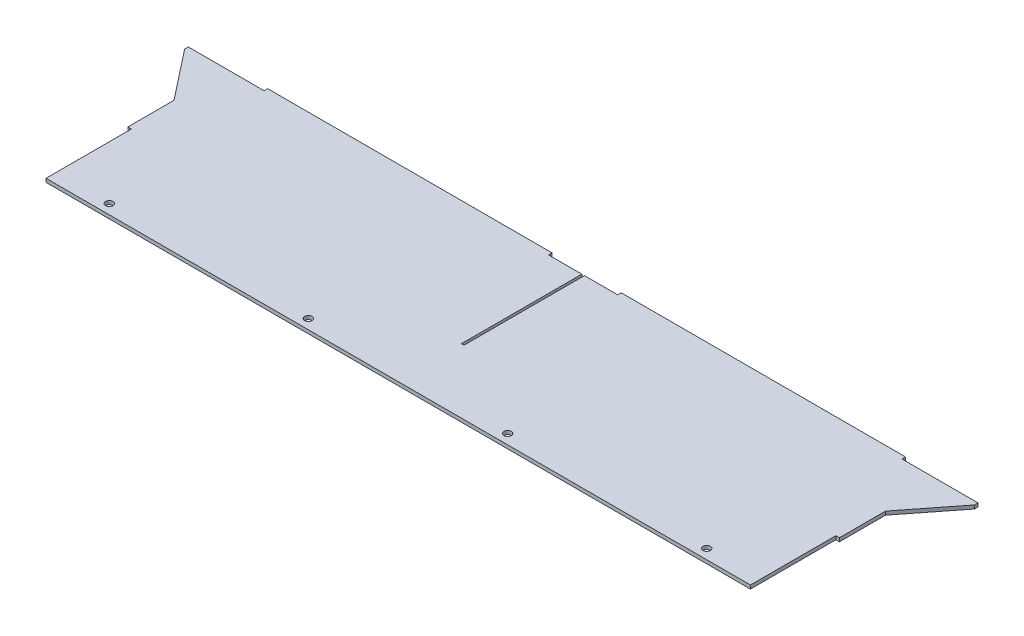
from build123d import *

# Parameters (mm, degrees)
SKETCH1_W            = 635.3556
SKETCH1_H            = 165.1
BOSS_EXTRUDE1_DEPTH  = 1.5875
SKETCH2_W            = 254
SKETCH2_H            = 3.175
BOSS_EXTRUDE2_DEPTH  = 3.175
BOSS_EXTRUDE3_DEPTH  = 3.175
SKETCH5_W            = 3.175
SKETCH5_H            = 76.2
SKETCH5_W_2          = 2.286
SKETCH5_H_2          = 107.442
CUT_EXTRUDE2_DEPTH   = 4.175
M6_CLEARANCE_HOLE1_D = 6.6
LPATTERN2_COUNT      = 4
LPATTERN2_PITCH      = 177.8


with BuildPart() as part:
    # Sketch1 → Boss-Extrude1 (new body, symmetric)
    with BuildSketch(Plane(origin=(0, 0, 0), x_dir=(1, 0, 0), z_dir=(0, 1, 0))):
        Rectangle(SKETCH1_W, SKETCH1_H)
    extrude(amount=BOSS_EXTRUDE1_DEPTH, both=True)

    # Sketch2 → Boss-Extrude2 (add)
    with BuildSketch(Plane(origin=(0, 0, -82.55), x_dir=(-1, 0, 0), z_dir=(0, 0, -1))):
        with Locations((-157.8229, 0)):
            Rectangle(SKETCH2_W, SKETCH2_H)
        with Locations((157.8229, 0)):
            Rectangle(SKETCH2_W, SKETCH2_H)
    extrude(amount=BOSS_EXTRUDE2_DEPTH)

    # Sketch3 → Boss-Extrude3 (add)
    with BuildSketch(Plane.XZ.offset(1.5875)):
        Polygon((317.6778, -82.55), (352.6028, -82.55), (352.6028, -79.375), (317.6778, -34.925), align=None)
    boss_extrude3 = extrude(amount=-BOSS_EXTRUDE3_DEPTH)

    # Mirror1: Boss-Extrude3 across plane
    add(boss_extrude3.mirror(Plane(origin=(0, 0, 0), x_dir=(0, 0, 1), z_dir=(1, 0, 0))))

    # Sketch5 → Cut-Extrude2 (cut, through all)
    with BuildSketch(Plane.XZ.offset(1.5875)):
        with Locations((316.0903, 44.45)):
            Rectangle(SKETCH5_W, SKETCH5_H)
        with Locations((-316.0903, 44.45)):
            Rectangle(SKETCH5_W, SKETCH5_H)
        with Locations((0, -28.829)):
            Rectangle(SKETCH5_W_2, SKETCH5_H_2)
    extrude(amount=-CUT_EXTRUDE2_DEPTH, mode=Mode.SUBTRACT)

    # M6 Clearance Hole1 (through all)
    with Locations(Plane(origin=(0, 1.5875, 0), x_dir=(1, 0, 0), z_dir=(0, 1, 0))):
        with Locations((266.7, -73.8124)):
            m6_clearance_hole1 = Hole(M6_CLEARANCE_HOLE1_D / 2)

    # LPattern2: M6 Clearance Hole1 ×4
    with Locations(*[(-i * LPATTERN2_PITCH, 0, 0) for i in range(1, LPATTERN2_COUNT)]):
        add(m6_clearance_hole1, mode=Mode.SUBTRACT)


solid = part.part
